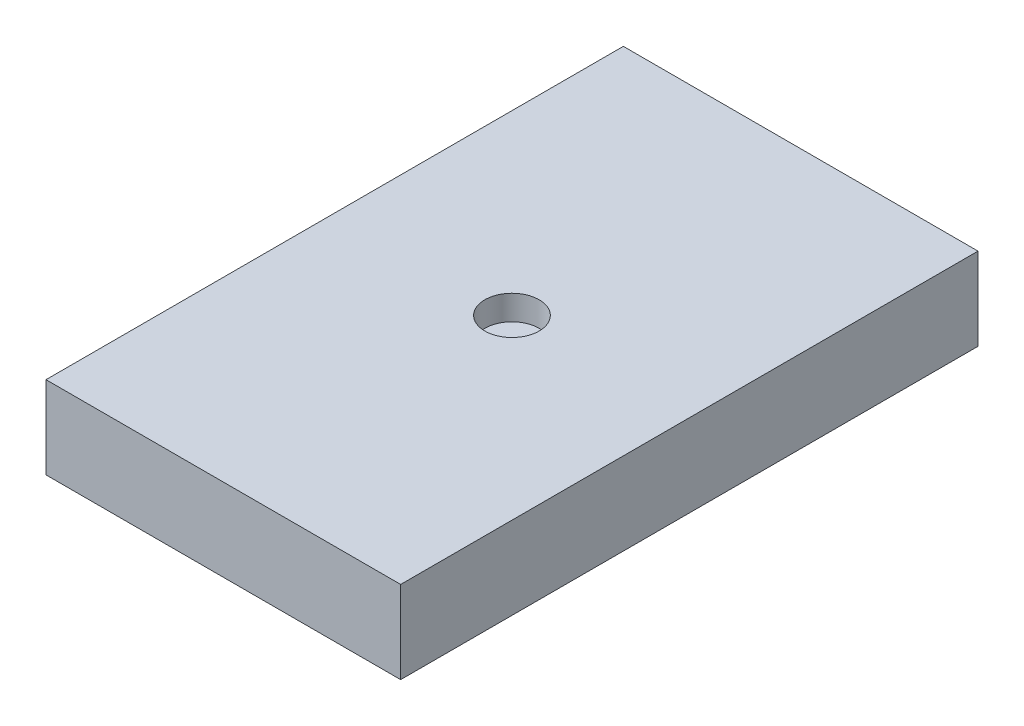
from build123d import *

# Parameters (mm, degrees)
SKETCH1_W           = 10.922
SKETCH1_H           = 17.78
BOSS_EXTRUDE1_DEPTH = 2.54
SKETCH2_R           = 0.835790113
CUT_EXTRUDE1_DEPTH  = 0.762


with BuildPart() as part:
    # Sketch1 → Boss-Extrude1 (new body)
    with BuildSketch(Plane(origin=(0, 0, 0), x_dir=(1, 0, 0), z_dir=(0, 1, 0))):
        Rectangle(SKETCH1_W, SKETCH1_H)
    extrude(amount=BOSS_EXTRUDE1_DEPTH)

    # Sketch2 → Cut-Extrude1 (cut)
    with BuildSketch(Plane(origin=(0, 2.54, 0), x_dir=(1, 0, 0), z_dir=(0, 1, 0))):
        Circle(SKETCH2_R)
    extrude(amount=-CUT_EXTRUDE1_DEPTH, mode=Mode.SUBTRACT)


solid = part.part
